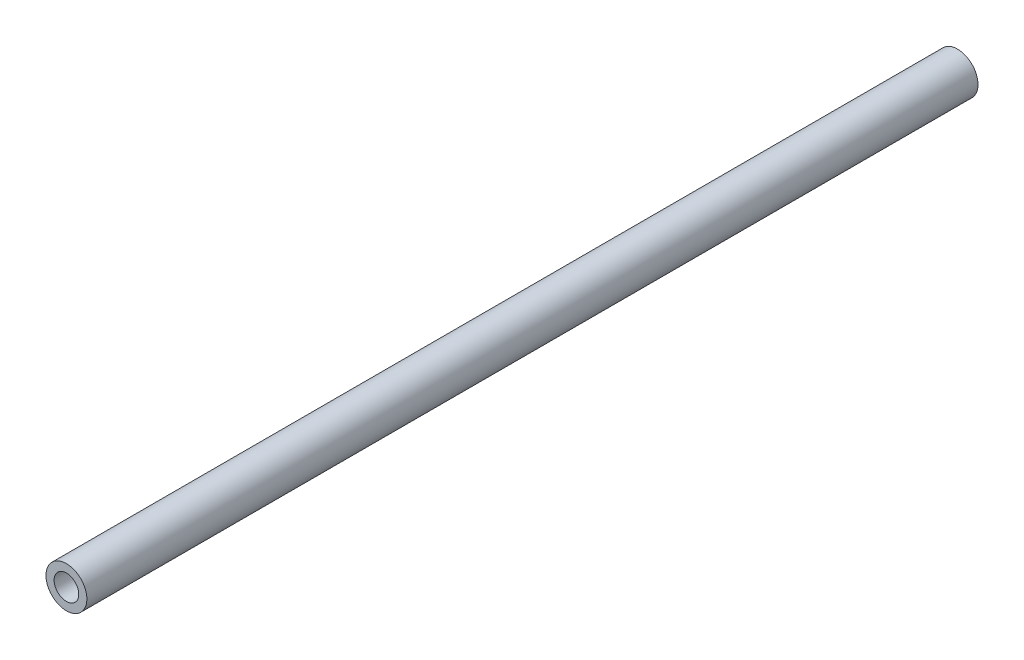
from build123d import *

# Parameters (mm, degrees)
SKETCH1_R           = 12.826813773
SKETCH1_R_2         = 7.731445382
BOSS_EXTRUDE1_DEPTH = 558.8


with BuildPart() as part:
    # Sketch1 → Boss-Extrude1 (new body)
    with BuildSketch(Plane.XY):
        with Locations((-14.793851931, 11.597649353)):
            Circle(SKETCH1_R)
        with Locations((-14.793851931, 11.597649353)):
            Circle(SKETCH1_R_2, mode=Mode.SUBTRACT)
    extrude(amount=BOSS_EXTRUDE1_DEPTH)


solid = part.part
